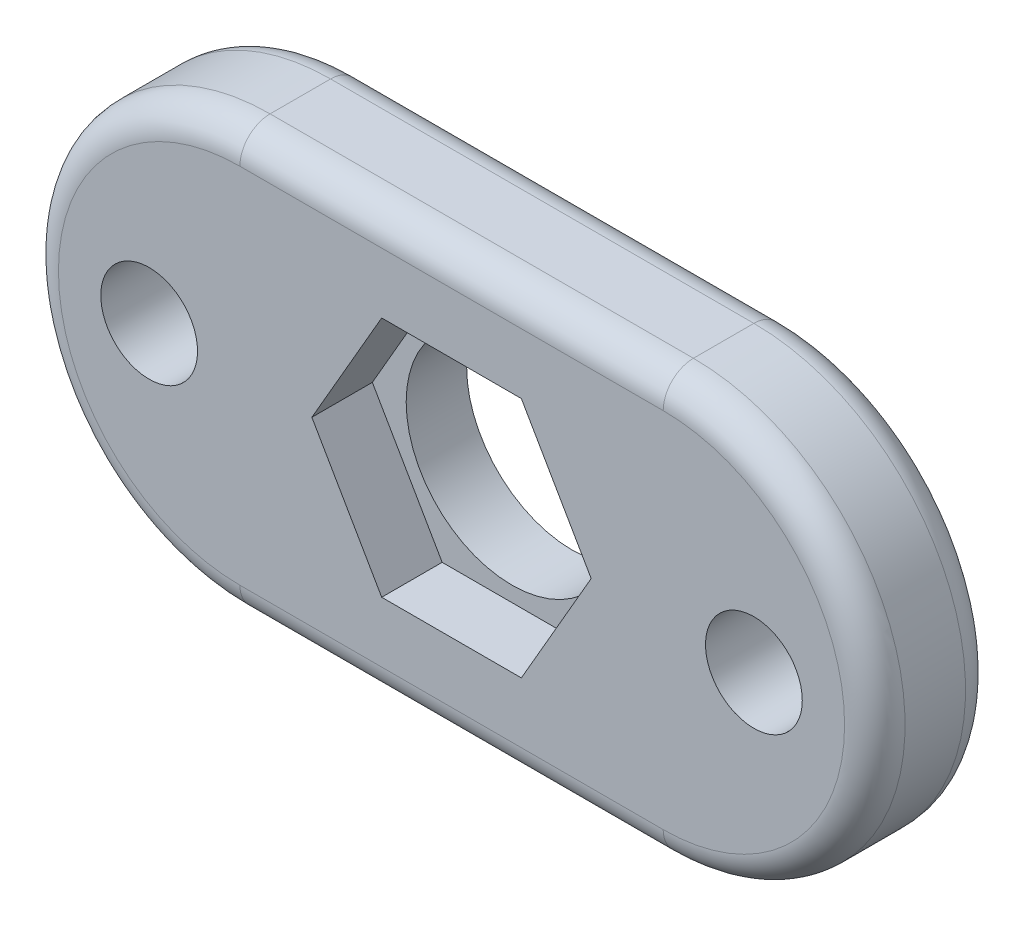
from build123d import *

# Parameters (mm, degrees)
BOSS_EXTRU_1_DEPTH      = 4
ESQUISSE3_R             = 3.5
ESQUISSE3_R_2           = 1.6
ENL_V_MAT_EXTRU_1_DEPTH = 5
ENL_V_MAT_EXTRU_2_DEPTH = 2
CONG_1_R                = 1


with BuildPart() as part:
    # Esquisse1 → Boss.-Extru.1 (new body)
    with BuildSketch(Plane.XY):
        with BuildLine():
            Line((-27.254178511, 7), (-13.254178511, 7))
            ThreePointArc((-13.254178511, 7), (-6.254178511, 0), (-13.254178511, -7))
            Line((-13.254178511, -7), (-27.254178511, -7))
            ThreePointArc((-27.254178511, -7), (-34.254178511, 0), (-27.254178511, 7))
        make_face()
    extrude(amount=BOSS_EXTRU_1_DEPTH)

    # Esquisse3 → Enlèv. mat.-Extru.1 (cut, through all)
    with BuildSketch(Plane.XY.offset(4)):
        with Locations((-20.254178511, 0)):
            Circle(ESQUISSE3_R)
        with Locations((-30.254178511, 0)):
            Circle(ESQUISSE3_R_2)
        with Locations((-10.254178511, 0)):
            Circle(ESQUISSE3_R_2)
    extrude(amount=-ENL_V_MAT_EXTRU_1_DEPTH, mode=Mode.SUBTRACT)

    # Esquisse4 → Enlèv. mat.-Extru.2 (cut)
    with BuildSketch(Plane.XY.offset(4)):
        Polygon((-22.563579588, 4), (-24.872980665, 0), (-22.563579588, -4), (-17.944777434, -4), (-15.635376357, 0), (-17.944777434, 4), align=None)
    extrude(amount=-ENL_V_MAT_EXTRU_2_DEPTH, mode=Mode.SUBTRACT)

    # Congé1
    cong_1_edges = [part.edges().sort_by_distance(p)[0] for p in [
        (-6.254178511, 0, 4),
        (-20.254178511, 7, 4),
        (-34.254178511, 0, 4),
        (-20.254178511, 7, 0),
        (-6.254178511, 0, 0),
        (-20.254178511, -7, 0),
        (-34.254178511, 0, 0),
        (-20.254178511, -7, 4),
    ]]
    fillet(cong_1_edges, radius=CONG_1_R)


solid = part.part
